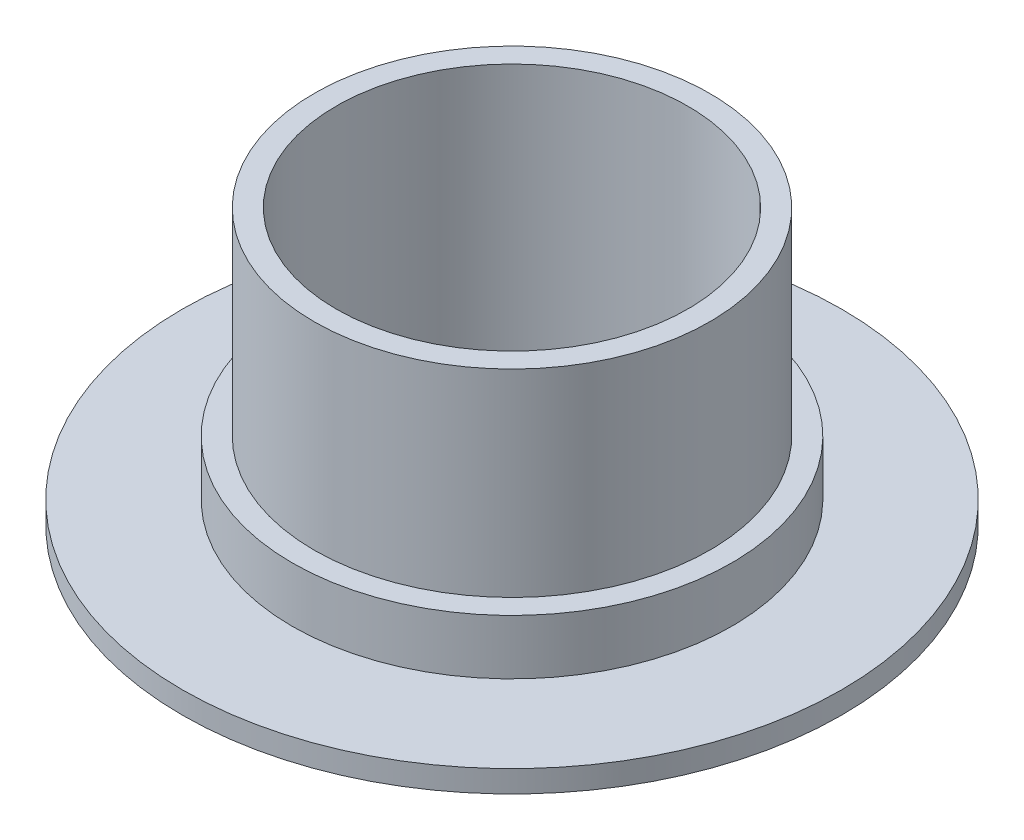
from build123d import *

# Parameters (mm, degrees)
SKETCH1_R           = 30
SKETCH1_R_2         = 20
BOSS_EXTRUDE1_DEPTH = 2
SKETCH2_R           = 20
SKETCH2_R_2         = 18
BOSS_EXTRUDE2_DEPTH = 7
SKETCH3_R           = 18
SKETCH3_R_2         = 16
BOSS_EXTRUDE3_DEPTH = 25


with BuildPart() as part:
    # Sketch1 → Boss-Extrude1 (new body)
    with BuildSketch(Plane(origin=(0, 0, 0), x_dir=(1, 0, 0), z_dir=(0, 1, 0))):
        Circle(SKETCH1_R)
        Circle(SKETCH1_R_2, mode=Mode.SUBTRACT)
    extrude(amount=BOSS_EXTRUDE1_DEPTH)

    # Sketch2 → Boss-Extrude2 (add)
    with BuildSketch(Plane(origin=(0, 0, 0), x_dir=(1, 0, 0), z_dir=(0, 1, 0))):
        Circle(SKETCH2_R)
        Circle(SKETCH2_R_2, mode=Mode.SUBTRACT)
    extrude(amount=BOSS_EXTRUDE2_DEPTH)

    # Sketch3 → Boss-Extrude3 (add)
    with BuildSketch(Plane(origin=(0, 0, 0), x_dir=(1, 0, 0), z_dir=(0, 1, 0))):
        Circle(SKETCH3_R)
        Circle(SKETCH3_R_2, mode=Mode.SUBTRACT)
    extrude(amount=BOSS_EXTRUDE3_DEPTH)


solid = part.part
